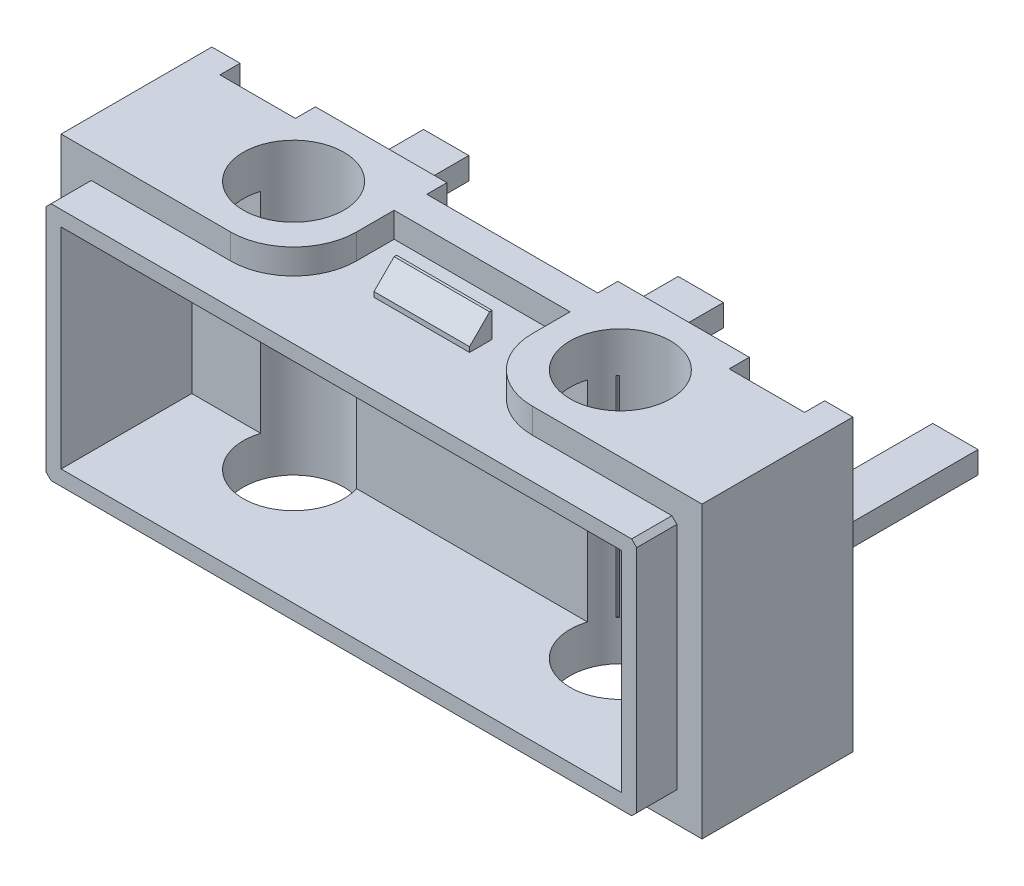
from build123d import *

# Parameters (mm, degrees)
ESQUISSE1_W                  = 12.75
ESQUISSE1_H                  = 5.77
BASE_EXTRUSION_DEPTH         = 3
ESQUISSE2_W                  = 1.5
ESQUISSE2_H                  = 0.4
ESQUISSE2_W_2                = 3.4
ENL_V_MAT_EXTRU_1_DEPTH      = 3.885
ENL_V_MAT_EXTRU_1_DEPTH_BACK = 3.885
COQUE1_T                     = -0.8
ESQUISSE3_W                  = 0.9
ESQUISSE3_H                  = 0.44
BOSS_EXTRU_1_DEPTH           = 3.75
ESQUISSE4_W                  = 11.75
ESQUISSE4_H                  = 4.77
ESQUISSE4_W_2                = 11.15
ESQUISSE4_H_2                = 4.17
BOSS_EXTRU_2_DEPTH           = 0.8
ENL_V_MAT_EXTRU_2_DEPTH      = 0.5
SYM_TRIE2_COPY_1_DEPTH       = 0.5
CHANFREIN1_SIZE              = 0.1
ESQUISSE6_W                  = 1.9
ESQUISSE6_H                  = 0.45
BOSS_EXTRU_3_DEPTH           = 0.5
CHANFREIN2_SIZE              = 0.4
CHANFREIN2_OF_SYM_TRIE3_SIZE = 0.4
ESQUISSE7_R                  = 1
ENL_V_MAT_EXTRU_3_DEPTH      = 3.885
ENL_V_MAT_EXTRU_3_DEPTH_BACK = 3.885


with BuildPart() as part:
    # Esquisse1 → Base-Extrusion (new body)
    with BuildSketch(Plane.XY):
        Rectangle(ESQUISSE1_W, ESQUISSE1_H)
    extrude(amount=-BASE_EXTRUSION_DEPTH)

    # Esquisse2 → Enlèv. mat.-Extru.1 (cut, two sides)
    with BuildSketch(Plane(origin=(0, 0, 0), x_dir=(1, 0, 0), z_dir=(0, 1, 0))) as enl_v_mat_extru_1_sk:
        with Locations((-5.065, 2.8)):
            Rectangle(ESQUISSE2_W, ESQUISSE2_H)
        with Locations((5.065, 2.8)):
            Rectangle(ESQUISSE2_W, ESQUISSE2_H)
        with Locations((0, 2.8)):
            Rectangle(ESQUISSE2_W_2, ESQUISSE2_H)
    extrude(amount=ENL_V_MAT_EXTRU_1_DEPTH, mode=Mode.SUBTRACT)
    extrude(enl_v_mat_extru_1_sk.sketch, amount=-ENL_V_MAT_EXTRU_1_DEPTH_BACK, mode=Mode.SUBTRACT)

    # Coque1
    coque1_openings = [part.faces().sort_by_distance(p)[0] for p in [
        (0, 0, 0),
    ]]
    offset(amount=COQUE1_T, openings=coque1_openings, kind=Kind.INTERSECTION)

    # Esquisse3 → Boss.-Extru.1 (add)
    with BuildSketch(Plane(origin=(0, 0, -2.6), x_dir=(-1, 0, 0), z_dir=(0, 0, -1))):
        with Locations((-5.065, 0)):
            Rectangle(ESQUISSE3_W, ESQUISSE3_H)
        with Locations((5.065, 0)):
            Rectangle(ESQUISSE3_W, ESQUISSE3_H)
        Rectangle(ESQUISSE3_W, ESQUISSE3_H)
    extrude(amount=BOSS_EXTRU_1_DEPTH)

    # Esquisse4 → Boss.-Extru.2 (add)
    with BuildSketch(Plane.XY):
        Rectangle(ESQUISSE4_W, ESQUISSE4_H)
        Rectangle(ESQUISSE4_W_2, ESQUISSE4_H_2, mode=Mode.SUBTRACT)
    extrude(amount=BOSS_EXTRU_2_DEPTH)

    # Esquisse5 → Enlèv. mat.-Extru.2 (cut)
    with BuildSketch(Plane(origin=(0, 2.885, 0), x_dir=(1, 0, 0), z_dir=(0, 1, 0))):
        with BuildLine():
            Line((3, 0), (0, 0))
            Line((0, 0), (0, 2))
            Line((0, 2), (1.75, 2))
            Line((1.75, 2), (1.75, 1.25))
            ThreePointArc((1.75, 1.25), (2.116116524, 0.366116524), (3, 0))
        make_face()
    enl_v_mat_extru_2 = extrude(amount=-ENL_V_MAT_EXTRU_2_DEPTH, mode=Mode.SUBTRACT)

    # Symétrie1: Enlèv. mat.-Extru.2 across plane
    add(enl_v_mat_extru_2.mirror(Plane(origin=(0, 0, 0), x_dir=(0, 0, 1), z_dir=(1, 0, 0))), mode=Mode.SUBTRACT)

    # Symétrie2: Enlèv. mat.-Extru.2 across plane
    add(enl_v_mat_extru_2.mirror(Plane.ZX), mode=Mode.SUBTRACT)

    # Symétrie2 copy 1 sketch → Symétrie2 copy 1 (cut)
    with BuildSketch(Plane(origin=(0, -2.885, 0), x_dir=(-1, 0, 0), z_dir=(0, -1, 0))):
        with BuildLine():
            Line((3, 0), (0, 0))
            Line((0, 0), (0, 2))
            Line((0, 2), (1.75, 2))
            Line((1.75, 2), (1.75, 1.25))
            ThreePointArc((1.75, 1.25), (2.116116524, 0.366116524), (3, 0))
        make_face()
    extrude(amount=-SYM_TRIE2_COPY_1_DEPTH, mode=Mode.SUBTRACT)

    # Chanfrein1
    chanfrein1_edges = [part.edges().sort_by_distance(p)[0] for p in [
        (5.875, -2.385, 0.4),
        (5.875, 2.385, 0.4),
        (-5.875, 2.385, 0.4),
        (-5.875, -2.385, 0.4),
    ]]
    chamfer(chanfrein1_edges, length=CHANFREIN1_SIZE)

    # Esquisse6 → Boss.-Extru.3 (add)
    with BuildSketch(Plane(origin=(0, 2.385, 0), x_dir=(-1, 0, 0), z_dir=(0, 1, 0))):
        with Locations((0, -1.025)):
            Rectangle(ESQUISSE6_W, ESQUISSE6_H)
    boss_extru_3 = extrude(amount=BOSS_EXTRU_3_DEPTH)

    # Chanfrein2
    chanfrein2_edges = [part.edges().sort_by_distance(p)[0] for p in [
        (0, 2.885, -0.8),
    ]]
    chamfer(chanfrein2_edges, length=CHANFREIN2_SIZE)

    # Symétrie3: Boss.-Extru.3 across plane
    add(boss_extru_3.mirror(Plane.ZX))

    # Chanfrein2 of Symétrie3
    chanfrein2_of_sym_trie3_edges = [part.edges().sort_by_distance(p)[0] for p in [
        (0, -2.885, -0.8),
    ]]
    chamfer(chanfrein2_of_sym_trie3_edges, length=CHANFREIN2_OF_SYM_TRIE3_SIZE)

    # Esquisse7 → Enlèv. mat.-Extru.3 (cut, two sides)
    with BuildSketch(Plane(origin=(0, 0, 0), x_dir=(1, 0, 0), z_dir=(0, 1, 0))) as enl_v_mat_extru_3_sk:
        with Locations(Location((3.25, 1.5, 0), (0, 0, 270))):  # turned: the seam where the file's is
            Circle(ESQUISSE7_R)
        with Locations(Location((-3.25, 1.5, 0), (0, 0, 90))):  # turned: the seam where the file's is
            Circle(ESQUISSE7_R)
    extrude(amount=ENL_V_MAT_EXTRU_3_DEPTH, mode=Mode.SUBTRACT)
    extrude(enl_v_mat_extru_3_sk.sketch, amount=-ENL_V_MAT_EXTRU_3_DEPTH_BACK, mode=Mode.SUBTRACT)


solid = part.part
